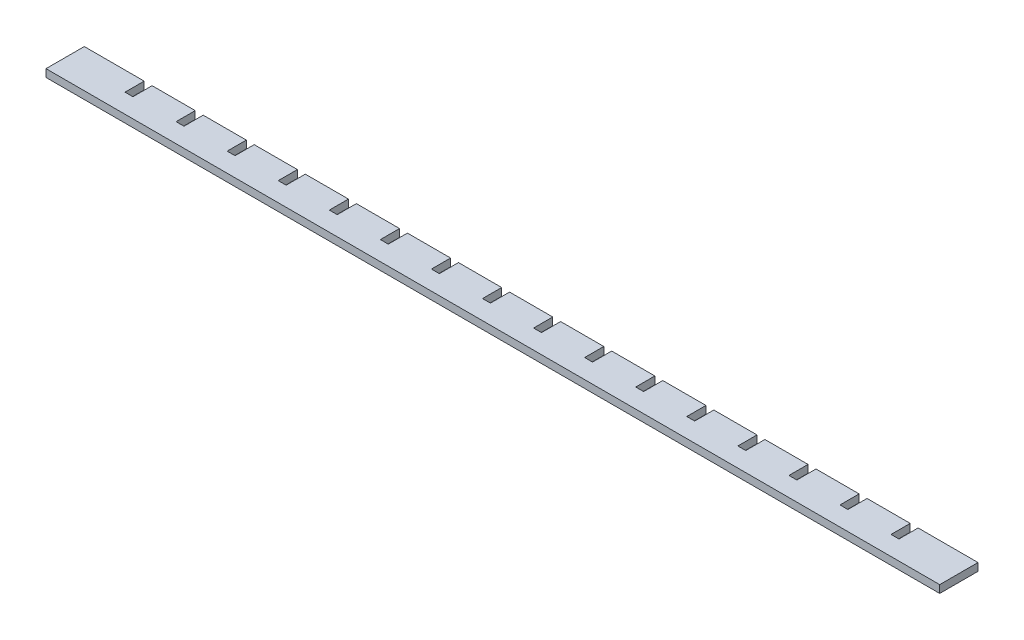
from build123d import *

# Parameters (mm, degrees)
AUFSATZ_LINEAR_AUSTRAGEN1_DEPTH = 3


with BuildPart() as part:
    # Skizze1 → Aufsatz-Linear austragen1 (new body)
    with BuildSketch(Plane(origin=(0, 0, 0), x_dir=(1, 0, 0), z_dir=(0, 1, 0))):
        Polygon((-109.380188679, 3.018867925), (-109.380188679, 10.518867925), (-126.280188679, 10.518867925), (-126.280188679, 3.018867925), (-129.380188679, 3.018867925), (-129.380188679, 10.518867925), (-152.830188679, 10.518867925), (-152.830188679, -4.481132075), (197.169811321, -4.481132075), (197.169811321, 10.518867925), (173.719811321, 10.518867925), (173.719811321, 3.018867925), (170.619811321, 3.018867925), (170.619811321, 10.518867925), (153.719811321, 10.518867925), (153.719811321, 3.018867925), (150.619811321, 3.018867925), (150.619811321, 10.518867925), (133.719811321, 10.518867925), (133.719811321, 3.018867925), (130.619811321, 3.018867925), (130.619811321, 10.518867925), (113.719811321, 10.518867925), (113.719811321, 3.018867925), (110.619811321, 3.018867925), (110.619811321, 10.518867925), (93.719811321, 10.518867925), (93.719811321, 3.018867925), (90.619811321, 3.018867925), (90.619811321, 10.518867925), (73.719811321, 10.518867925), (73.719811321, 3.018867925), (70.619811321, 3.018867925), (70.619811321, 10.518867925), (53.719811321, 10.518867925), (53.719811321, 3.018867925), (50.619811321, 3.018867925), (50.619811321, 10.518867925), (33.719811321, 10.518867925), (33.719811321, 3.018867925), (30.619811321, 3.018867925), (30.619811321, 10.518867925), (13.719811321, 10.518867925), (13.719811321, 3.018867925), (10.619811321, 3.018867925), (10.619811321, 10.518867925), (-6.280188679, 10.518867925), (-6.280188679, 3.018867925), (-9.380188679, 3.018867925), (-9.380188679, 10.518867925), (-26.280188679, 10.518867925), (-26.280188679, 3.018867925), (-29.380188679, 3.018867925), (-29.380188679, 10.518867925), (-46.280188679, 10.518867925), (-46.280188679, 3.018867925), (-49.380188679, 3.018867925), (-49.380188679, 10.518867925), (-66.280188679, 10.518867925), (-66.280188679, 3.018867925), (-69.380188679, 3.018867925), (-69.380188679, 10.518867925), (-86.280188679, 10.518867925), (-86.280188679, 3.018867925), (-89.380188679, 3.018867925), (-89.380188679, 10.518867925), (-106.280188679, 10.518867925), (-106.280188679, 3.018867925), align=None)
    extrude(amount=AUFSATZ_LINEAR_AUSTRAGEN1_DEPTH)


solid = part.part
